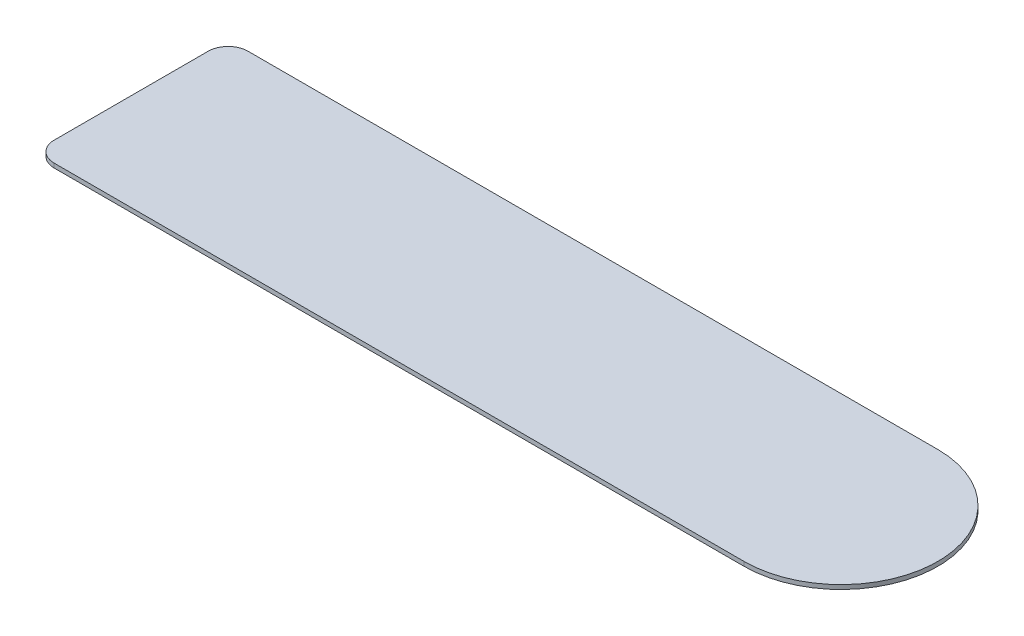
from build123d import *

# Parameters (mm, degrees)
BOSS_EXTRUDE1_DEPTH = 1.5


with BuildPart() as part:
    # Sketch1 → Boss-Extrude1 (new body)
    with BuildSketch(Plane(origin=(0, 0, 0), x_dir=(1, 0, 0), z_dir=(0, 1, 0))):
        with BuildLine():
            Line((360, 33.999992985), (118, 33.999992985))
            ThreePointArc((118, 33.999992985), (113.050252532, 31.949740453), (111, 26.999992985))
            Line((111, 26.999992985), (111, -27.000001075))
            ThreePointArc((111, -27.000001075), (113.050252532, -31.949748543), (118, -34.000001075))
            Line((118, -34.000001075), (360, -34.000001075))
            ThreePointArc((360, -34.000001075), (393.99999703, -4.045e-06), (360, 33.999992985))
        make_face()
    extrude(amount=BOSS_EXTRUDE1_DEPTH)


solid = part.part
